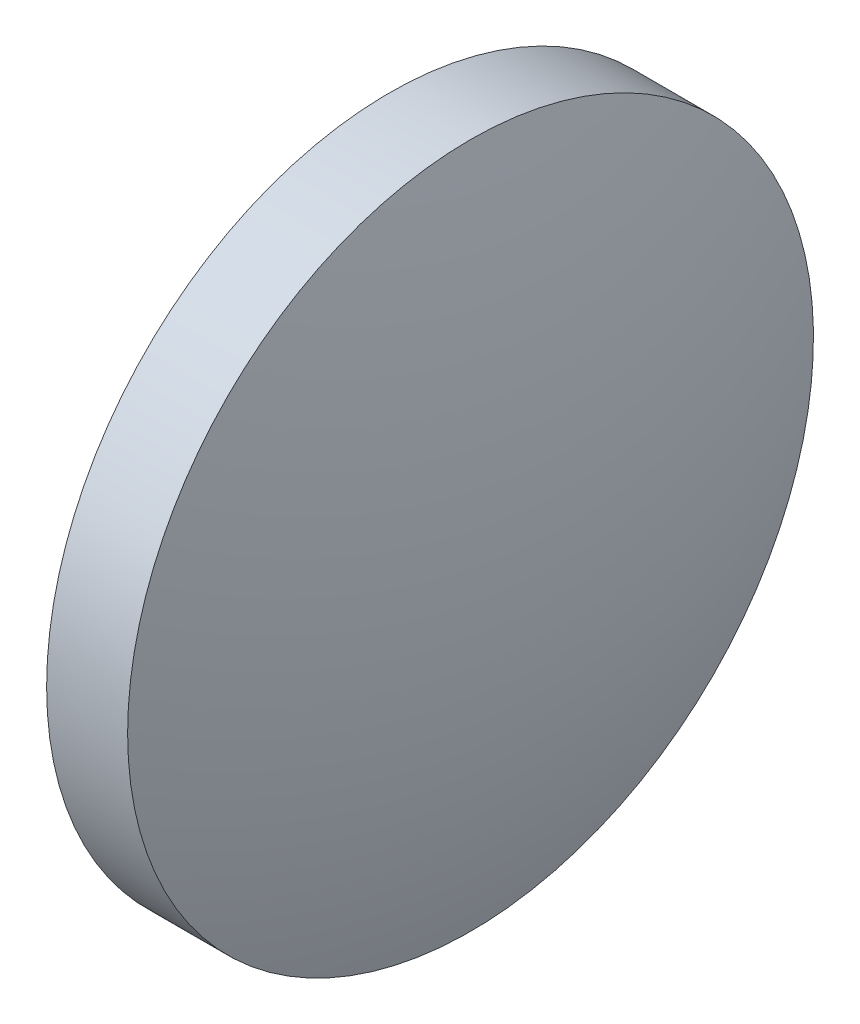
from build123d import *


with BuildPart() as part:
    # 草图1 → 旋转1 (revolve)
    with BuildSketch(Plane.XY):
        with BuildLine():
            Line((606.638649393, 118.737386698), (606.638649393, 125.087386698))
            Line((606.638649393, 125.087386698), (608.138649393, 125.087386698))
            ThreePointArc((608.138649393, 125.087386698), (608.887118317, 121.951515662), (609.138649393, 118.737386698))
            Line((609.138649393, 118.737386698), (606.638649393, 118.737386698))
        make_face()
    revolve(axis=Axis((604.378118247, 118.737386698, 0), (1, 0, 0)))


solid = part.part
